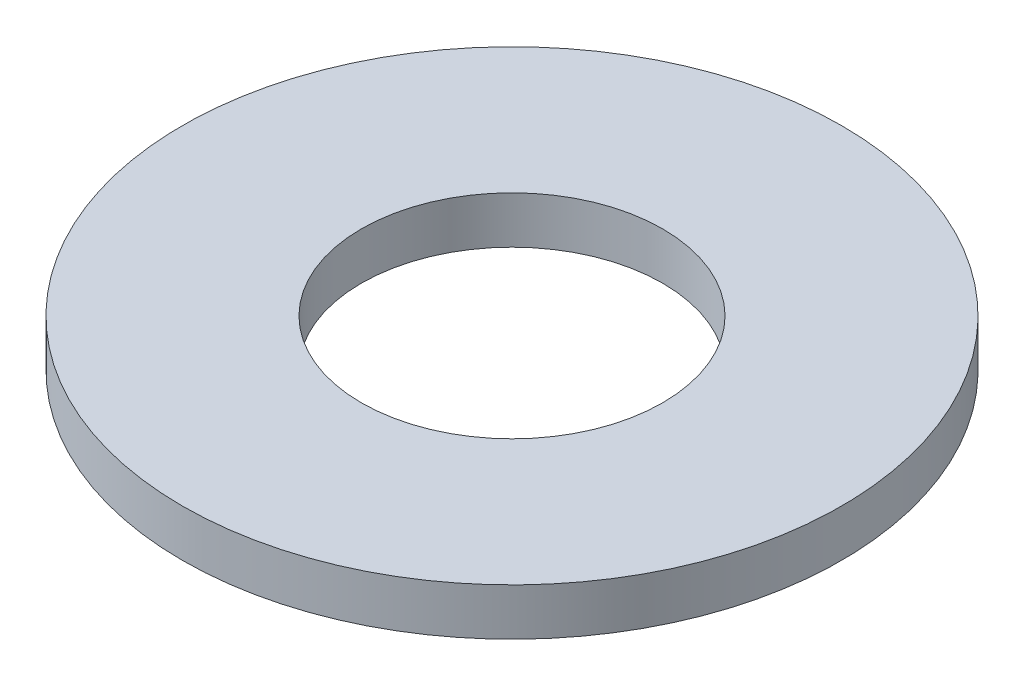
from build123d import *

# Parameters (mm, degrees)
SKETCH_1_R      = 3.5
SKETCH_1_R_2    = 1.6
EXTRUDE_1_DEPTH = 0.5


with BuildPart() as part:
    # 草图1 → 凸台-拉伸1 (new body)
    with BuildSketch(Plane(origin=(0, 0, 0), x_dir=(1, 0, 0), z_dir=(0, 1, 0))):
        Circle(SKETCH_1_R)
        Circle(SKETCH_1_R_2, mode=Mode.SUBTRACT)
    extrude(amount=EXTRUDE_1_DEPTH)


solid = part.part
